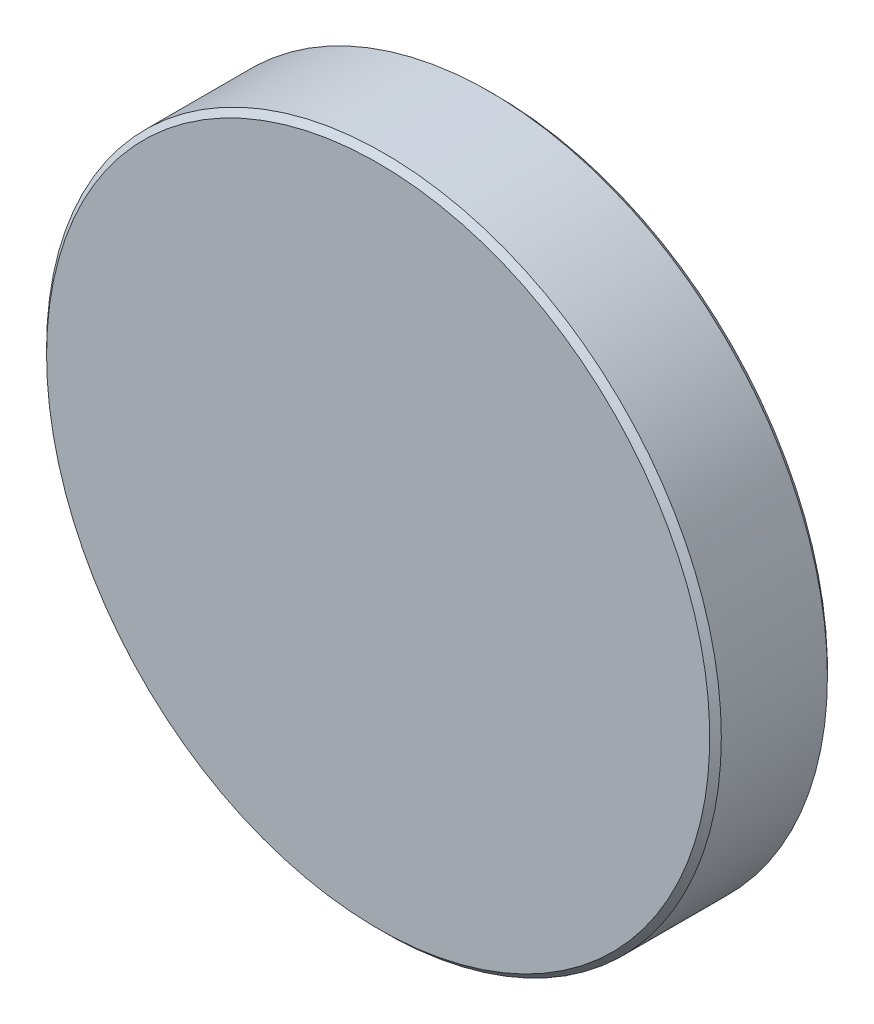
from build123d import *


with BuildPart() as part:
    # Sketch5 → Revolve2 (revolve)
    with BuildSketch(Plane(origin=(0, 0, 0), x_dir=(-1, 0, 0), z_dir=(0, -1, 0))):
        Polygon((-6.25, -0.245633188), (0, -0.245633188), (0, 1.972707424), (-6.25, 1.972707424), (-6.359170306, 1.863537118), (-6.359170306, -0.136462882), align=None)
    revolve(axis=Axis((0, 0, 0.245633188), (0, 0, -1)))


solid = part.part
